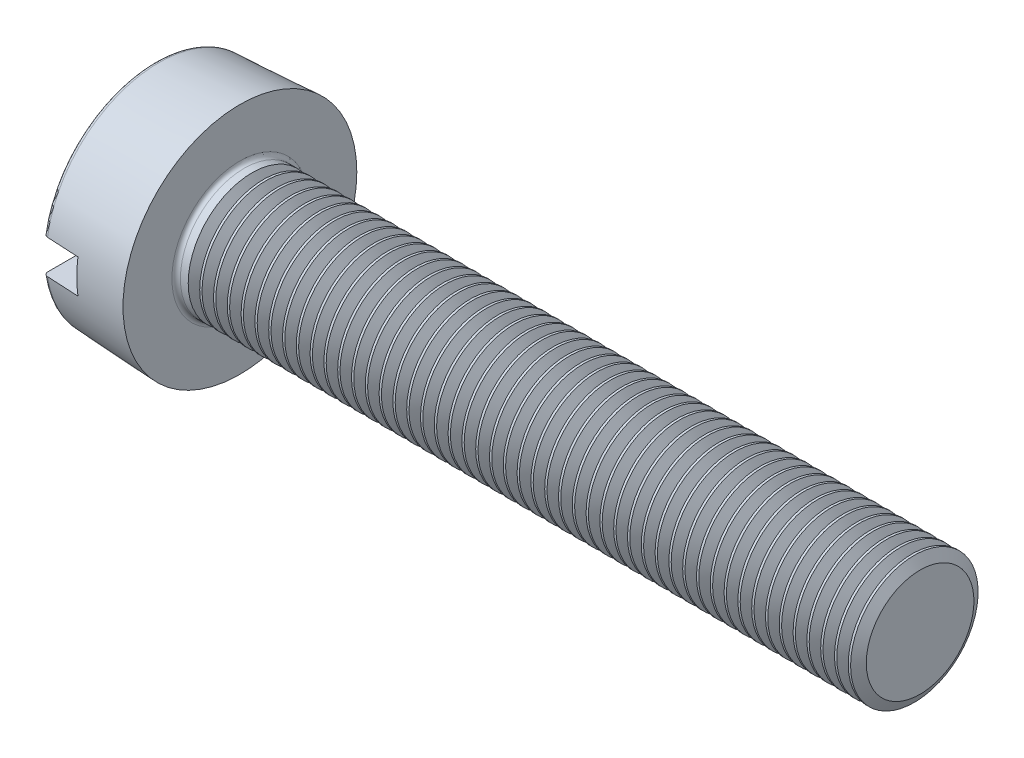
from build123d import *

# Parameters (mm, degrees)
SKETCH2_R        = 2.75
BASEHEAD_DEPTH   = 2
BASEHEAD_TAPER   = 3
SKETCH3_R        = 1.5
BASEBODY_DEPTH   = 16
SKETCH4_W        = 0.8
SKETCH4_H        = 0.85
SLOT_DEPTH       = 3.7500001
SLOT_DEPTH_BACK  = 3.7500001
HEADFILLET_R     = 0.1
LPATTERN10_COUNT = 49
LPATTERN10_PITCH = 0.3246


with BuildPart() as part:
    # Sketch2 → BaseHead (new body)
    with BuildSketch(Plane(origin=(2, 0, 0), x_dir=(0, 0, -1), z_dir=(1, 0, 0))):
        Circle(SKETCH2_R)
    extrude(amount=-BASEHEAD_DEPTH, taper=BASEHEAD_TAPER)

    # Sketch3 → BaseBody (add)
    with BuildSketch(Plane(origin=(2, -1.110095321, -1.354392991), x_dir=(0, 0, -1), z_dir=(1, 0, 0))):
        with Locations((-1.354392991, 1.110095321)):
            Circle(SKETCH3_R)
    extrude(amount=BASEBODY_DEPTH)

    # Sketch4 → Slot (cut, two sides)
    with BuildSketch(Plane(origin=(-1.9, -1.9, 0), x_dir=(0, 1, 0), z_dir=(0, 0, 1))) as slot_sk:
        with Locations((1.9, -2.325)):
            Rectangle(SKETCH4_W, SKETCH4_H)
    extrude(amount=SLOT_DEPTH, mode=Mode.SUBTRACT)
    extrude(slot_sk.sketch, amount=-SLOT_DEPTH_BACK, mode=Mode.SUBTRACT)

    # HeadFillet
    headfillet_edges = [part.edges().sort_by_distance(p)[0] for p in [
        (2, 0, 1.5),
        (0, -2.645184441, 0),
        (0, 2.645184441, 0),
    ]]
    fillet(headfillet_edges, radius=HEADFILLET_R)

    # Sketch5 → Cut-Revolve10 (revolve, cut)
    with BuildSketch(Plane.XY):
        Polygon((18.13525, 1.5), (18.13525, 1.7705), (17.86475, 1.7705), (17.86475, 1.5), (18, 1.265740128), align=None)
    cut_revolve10 = revolve(axis=Axis((0, 0, 0), (1, 0, 0)), mode=Mode.SUBTRACT)

    # LPattern10: Cut-Revolve10 ×49
    with Locations(*[(-i * LPATTERN10_PITCH, 0, 0) for i in range(1, LPATTERN10_COUNT)]):
        add(cut_revolve10, mode=Mode.SUBTRACT)


solid = part.part
